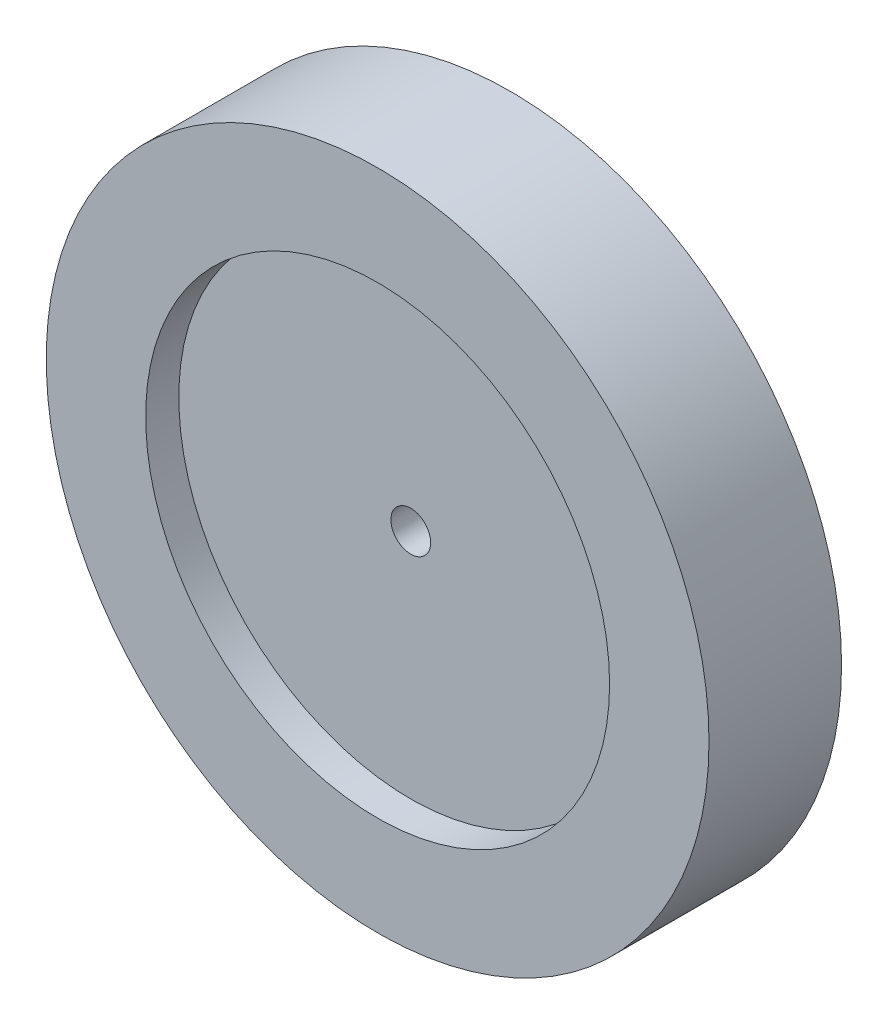
from build123d import *

# Parameters (mm, degrees)
SKETCH1_R           = 50
BOSS_EXTRUDE1_DEPTH = 10
SKETCH2_R           = 35
CUT_EXTRUDE1_DEPTH  = 5
SKETCH3_R           = 7.5
BOSS_EXTRUDE2_DEPTH = 20
CUT_EXTRUDE2_REACH  = 37
SKETCH4_R           = 3


with BuildPart() as part:
    # Sketch1 → Boss-Extrude1 (new body, symmetric)
    with BuildSketch(Plane.XY):
        Circle(SKETCH1_R)
    extrude(amount=BOSS_EXTRUDE1_DEPTH, both=True)

    # Sketch2 → Cut-Extrude1 (cut)
    with BuildSketch(Plane.XY.offset(10)):
        Circle(SKETCH2_R)
    cut_extrude1 = extrude(amount=-CUT_EXTRUDE1_DEPTH, mode=Mode.SUBTRACT)

    # Mirror1: Cut-Extrude1 across plane
    add(cut_extrude1.mirror(Plane.XY), mode=Mode.SUBTRACT)

    # Sketch3 → Boss-Extrude2 (add)
    with BuildSketch(Plane(origin=(0, 0, -5), x_dir=(-1, 0, 0), z_dir=(0, 0, -1))):
        Circle(SKETCH3_R)
    extrude(amount=BOSS_EXTRUDE2_DEPTH)

    # Sketch4 → Cut-Extrude2 (cut, up to next)
    with BuildSketch(Plane(origin=(0, 0, -25), x_dir=(-1, 0, 0), z_dir=(0, 0, -1)), mode=Mode.PRIVATE) as cut_extrude2_sk1:
        Circle(SKETCH4_R)
    cut_extrude2_tool1 = extrude(cut_extrude2_sk1.sketch, amount=-CUT_EXTRUDE2_REACH, mode=Mode.PRIVATE) & part.part
    add(cut_extrude2_tool1.solids().sort_by_distance((0, 0, -25))[0], mode=Mode.SUBTRACT)


solid = part.part
